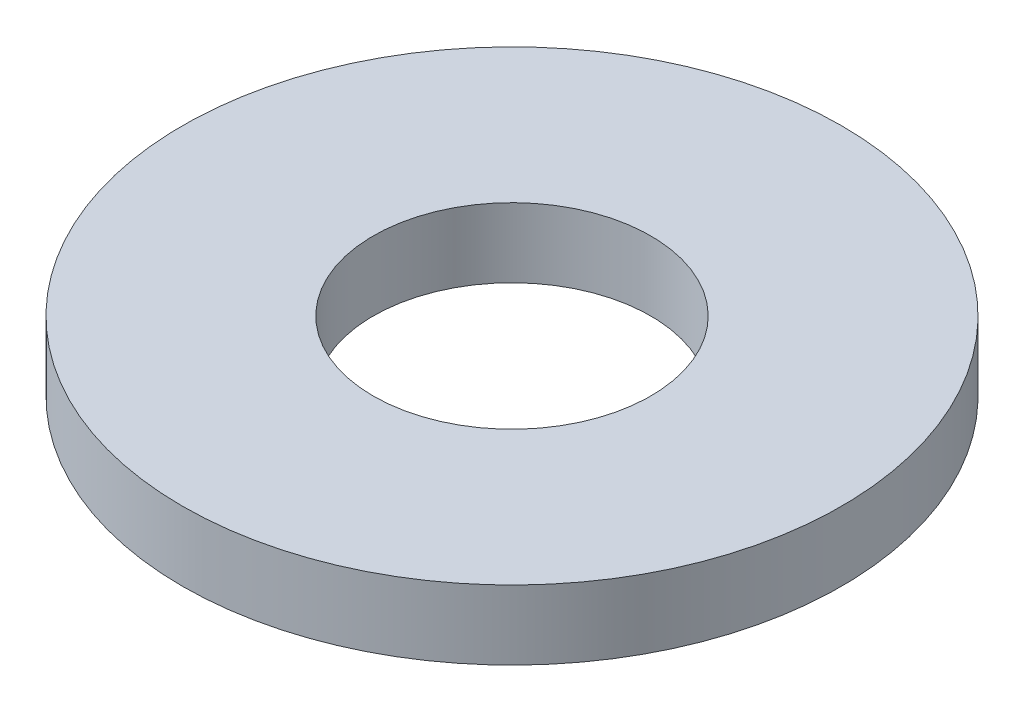
from build123d import *

# Parameters (mm, degrees)
SKETCH1_R           = 9.5
SKETCH1_R_2         = 4
BOSS_EXTRUDE1_DEPTH = 2


with BuildPart() as part:
    # Sketch1 → Boss-Extrude1 (new body)
    with BuildSketch(Plane(origin=(0, 0, 0), x_dir=(1, 0, 0), z_dir=(0, 1, 0))):
        Circle(SKETCH1_R)
        Circle(SKETCH1_R_2, mode=Mode.SUBTRACT)
    extrude(amount=BOSS_EXTRUDE1_DEPTH)


solid = part.part
